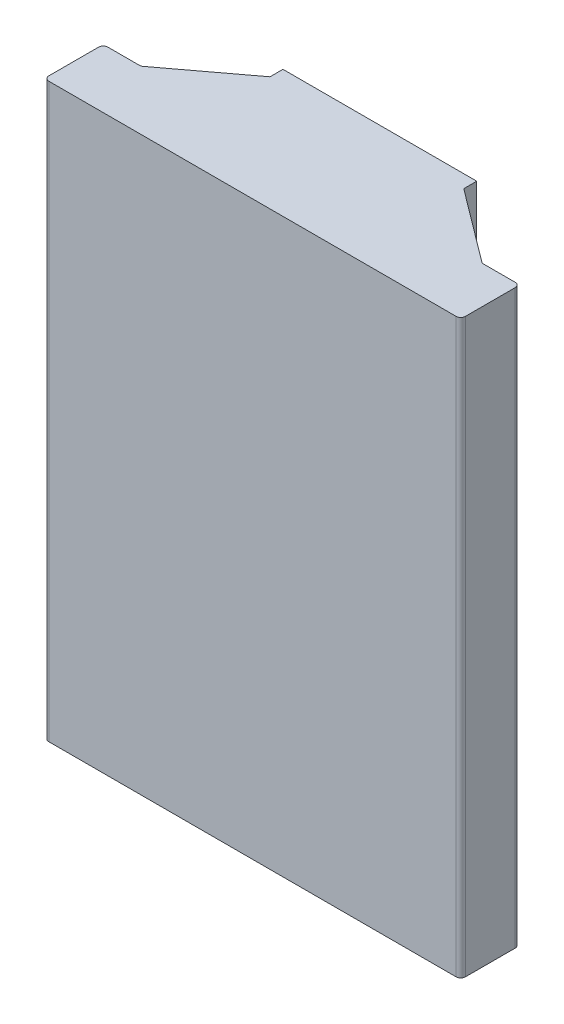
from build123d import *

# Parameters (mm, degrees)
BOSS_EXTRUDE1_DEPTH = 60
BOSS_EXTRUDE2_DEPTH = 2
FILLET1_R           = 0.5


with BuildPart() as part:
    # Sketch2 → Boss-Extrude1 (new body)
    with BuildSketch(Plane(origin=(0, 0, 0), x_dir=(1, 0, 0), z_dir=(0, 1, 0))):
        Polygon((-20.575, 0), (20.575, 0), (20.575, 2.4), (17.825, 2.4), (8.5, 9.4), (8.5, 11.805044241), (10.5, 11.805044241), (10.5, 10.399464037), (18.492143163, 4.4), (22.575, 4.4), (22.575, -2), (-22.575, -2), (-22.575, 4.4), (-18.492143163, 4.4), (-10.5, 10.399464037), (-10.5, 11.805044241), (-8.5, 11.805044241), (-8.5, 9.4), (-17.825, 2.4), (-20.575, 2.4), align=None)
    extrude(amount=BOSS_EXTRUDE1_DEPTH)

    # Sketch4 → Boss-Extrude2 (add)
    with BuildSketch(Plane(origin=(0, 60, 0), x_dir=(1, 0, 0), z_dir=(0, 1, 0))):
        Polygon((-22.575, 4.4), (-22.575, -2), (22.575, -2), (22.575, 4.4), (18.492143163, 4.4), (10.5, 10.399464037), (10.5, 11.805044241), (-10.5, 11.805044241), (-10.5, 10.399464037), (-18.492143163, 4.4), align=None)
    extrude(amount=BOSS_EXTRUDE2_DEPTH)

    # Fillet1
    fillet1_edges = [part.edges().sort_by_distance(p)[0] for p in [
        (8.5, 30, -9.4),
        (18.492143163, 31, -4.4),
        (22.575, 31, -4.4),
        (22.575, 31, 2),
        (-22.575, 31, 2),
        (-22.575, 31, -4.4),
        (-18.492143163, 31, -4.4),
        (-8.5, 30, -9.4),
        (-20.575, 30, -2.4),
        (-20.575, 30, 0),
        (20.575, 30, 0),
        (20.575, 30, -2.4),
    ]]
    fillet(fillet1_edges, radius=FILLET1_R)


solid = part.part
